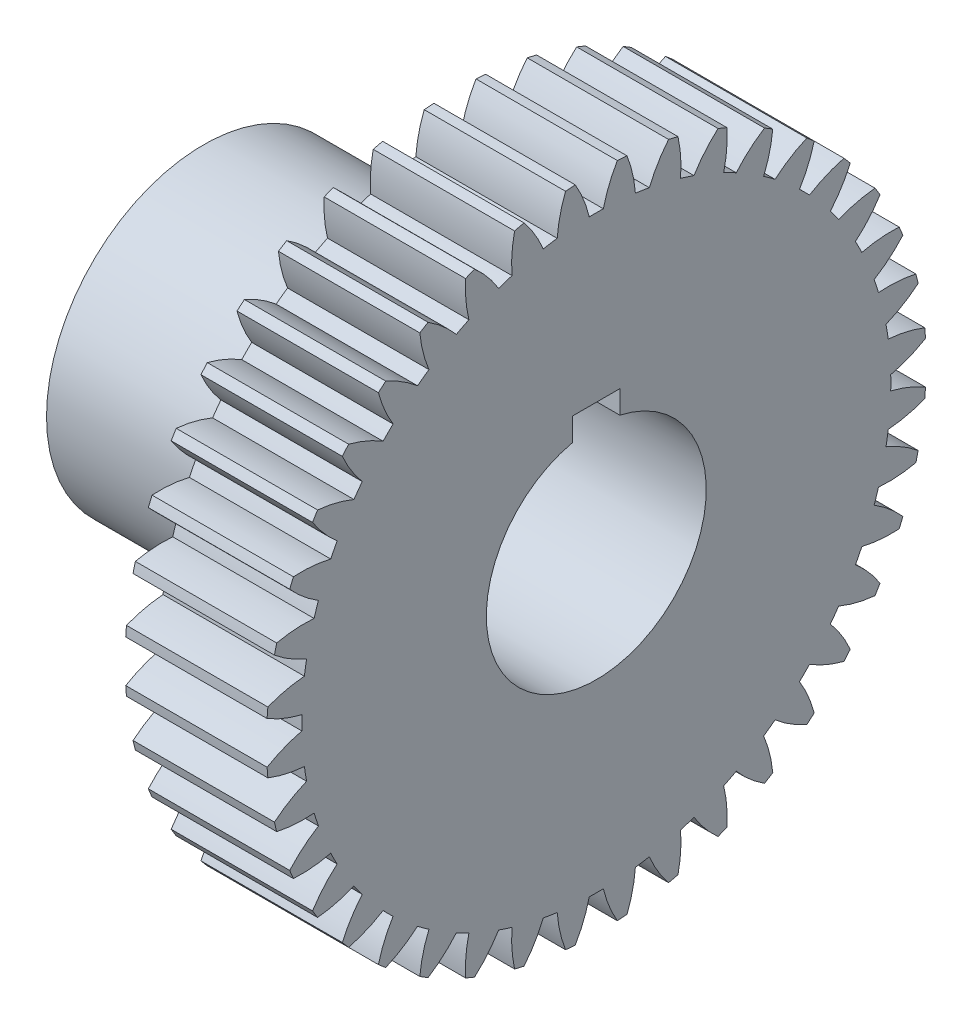
from build123d import *

# Parameters (mm, degrees)
BASPROSKE_W      = 9
BASPROSKE_H      = 21
TOOTHCUT_DEPTH   = 32.032241298
TEETHCUTS_COUNT  = 40
TEETHCUTS_ANGLE  = 351
HUBNEAONESKE_R   = 10
HUBNEARONE_DEPTH = 16.0000508
BORSKE_R         = 7
BORE_DEPTH       = 25.0000508
KEYSKE_W         = 3
KEYSKE_H         = 8.3
KEYWAY_DEPTH     = 25.0000508


with BuildPart() as part:
    # BasProSke → Base-Revolve (revolve)
    with BuildSketch(Plane(origin=(0, 0, 0), x_dir=(1, 0, 0), z_dir=(0, 1, 0)), mode=Mode.PRIVATE) as base_revolve_sk:
        with Locations((4.5, 10.5)):
            Rectangle(BASPROSKE_W, BASPROSKE_H)
    revolve(base_revolve_sk.sketch.rotate(Axis((-10, 0, 0), (1, 0, 0)), 180), axis=Axis((-10, 0, 0), (1, 0, 0)))

    # TooCutSke → ToothCut (cut, through all)
    with BuildSketch(Plane(origin=(0, 0, 0), x_dir=(0, 0, -1), z_dir=(1, 0, 0))):
        with BuildLine():
            ThreePointArc((0.448673268, 18.74363074), (0, 18.749), (-0.448673268, 18.74363074))
            ThreePointArc((-0.448673268, 18.74363074), (-0.816786816, 19.89705013), (-1.354745081, 20.981708961))
            ThreePointArc((-1.354745081, 20.981708961), (0, 21.0254), (1.354745081, 20.981708961))
            ThreePointArc((1.354745081, 20.981708961), (0.816786816, 19.89705013), (0.448673268, 18.74363074))
        make_face()
    toothcut = extrude(amount=TOOTHCUT_DEPTH, mode=Mode.SUBTRACT)

    # TeethCuts: ToothCut ×40 about axis
    teethcuts_axis = Axis((-10, 0, 0), (1, 0, 0))
    for i in range(1, TEETHCUTS_COUNT):
        add(toothcut.rotate(teethcuts_axis, i * TEETHCUTS_ANGLE / (TEETHCUTS_COUNT - 1)), mode=Mode.SUBTRACT)

    # HubNeaOneSke → HubNearOne (add)
    with BuildSketch(Plane.ZY):
        with Locations(Location((0, 0, 0), (0, 0, 180))):
            Circle(HUBNEAONESKE_R)
    extrude(amount=HUBNEARONE_DEPTH)

    # BorSke → Bore (cut, symmetric)
    with BuildSketch(Plane(origin=(0, 0, 0), x_dir=(0, 0, -1), z_dir=(1, 0, 0))):
        with Locations(Location((0, 0, 0), (0, 0, 180))):
            Circle(BORSKE_R)
    extrude(amount=BORE_DEPTH, both=True, mode=Mode.SUBTRACT)

    # KeySke → Keyway (cut, symmetric)
    with BuildSketch(Plane(origin=(0, 0, 0), x_dir=(0, 0, -1), z_dir=(1, 0, 0))):
        with Locations((0, 4.15)):
            Rectangle(KEYSKE_W, KEYSKE_H)
    extrude(amount=KEYWAY_DEPTH, both=True, mode=Mode.SUBTRACT)


solid = part.part
